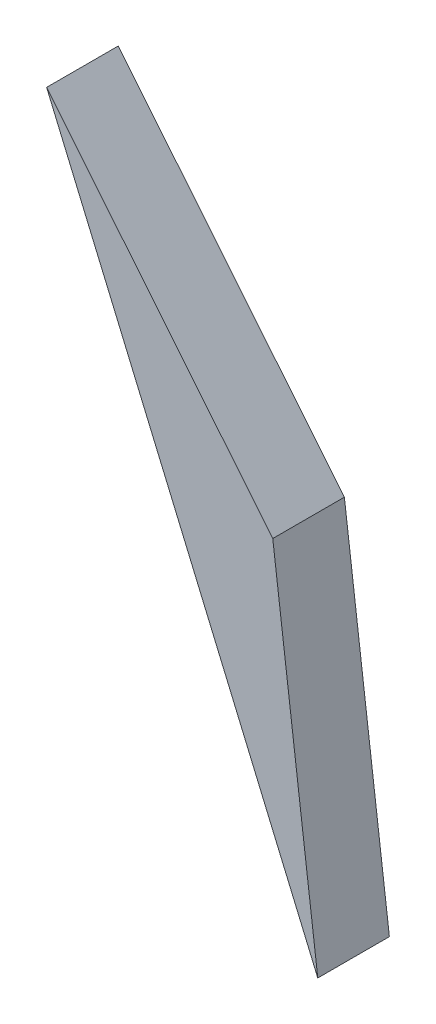
from build123d import *

# Parameters (mm, degrees)
BOSS_EXTRU_1_DEPTH = 3


with BuildPart() as part:
    # Esquisse1 → Boss.-Extru.1 (new body)
    with BuildSketch(Plane.XY):
        Polygon((-12.342477105, 10.402420385), (-0.983865114, -16.227661982), (-2.86929474, -1.227661982), align=None)
    extrude(amount=BOSS_EXTRU_1_DEPTH)


solid = part.part
